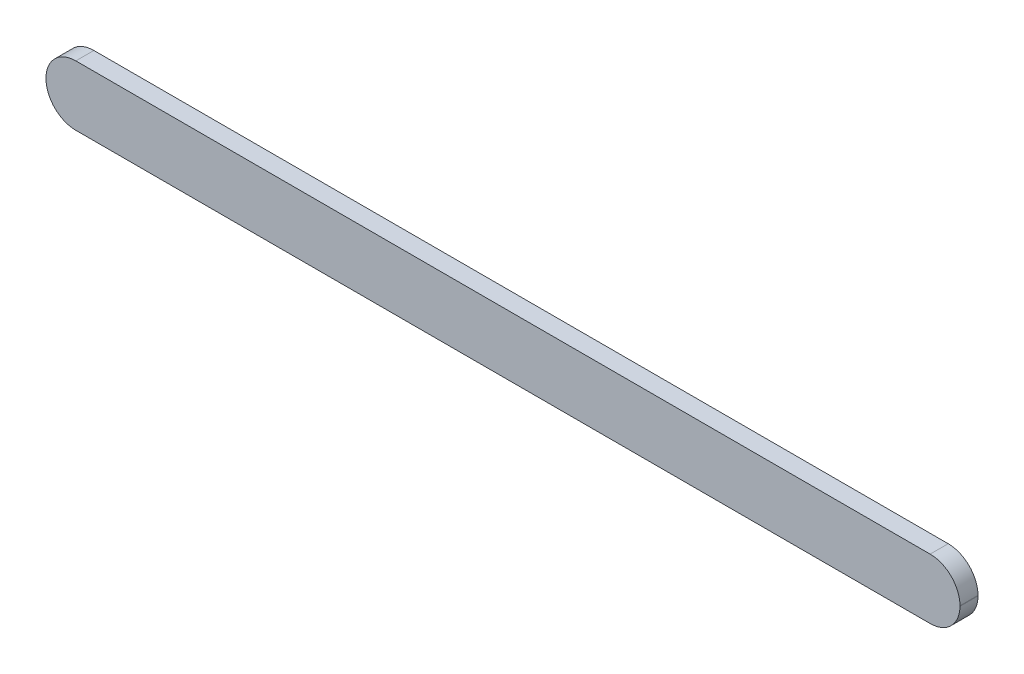
from build123d import *

# Parameters (mm, degrees)
BOSS_EXTRUDE1_DEPTH = 19.05
SKETCH3_R           = 16.66875
CUT_EXTRUDE1_DEPTH  = 9.525


with BuildPart() as part:
    # Sketch2 → Boss-Extrude1 (new body)
    with BuildSketch(Plane.XY):
        with BuildLine():
            Line((31.496, 0), (933.704, 0))
            ThreePointArc((933.704, 0), (955.97503518, -9.22496482), (965.2, -31.496))
            Line((965.2, -31.496), (965.2, -32.004))
            ThreePointArc((965.2, -32.004), (955.97503518, -54.27503518), (933.704, -63.5))
            Line((933.704, -63.5), (31.496, -63.5))
            ThreePointArc((31.496, -63.5), (9.22496482, -54.27503518), (0, -32.004))
            Line((0, -32.004), (0, -31.496))
            ThreePointArc((0, -31.496), (9.22496482, -9.22496482), (31.496, 0))
        make_face()
    extrude(amount=BOSS_EXTRUDE1_DEPTH)

    # Sketch3 → Cut-Extrude1 (cut)
    with BuildSketch(Plane.XY):
        with Locations((844.55, -31.75)):
            Circle(SKETCH3_R)
        with Locations((723.9, -31.75)):
            Circle(SKETCH3_R)
        with Locations((603.25, -31.75)):
            Circle(SKETCH3_R)
        with Locations((482.6, -31.75)):
            Circle(SKETCH3_R)
        with Locations((361.95, -31.75)):
            Circle(SKETCH3_R)
        with Locations((241.3, -31.75)):
            Circle(SKETCH3_R)
        with Locations((120.65, -31.75)):
            Circle(SKETCH3_R)
    extrude(amount=CUT_EXTRUDE1_DEPTH, mode=Mode.SUBTRACT)


solid = part.part
